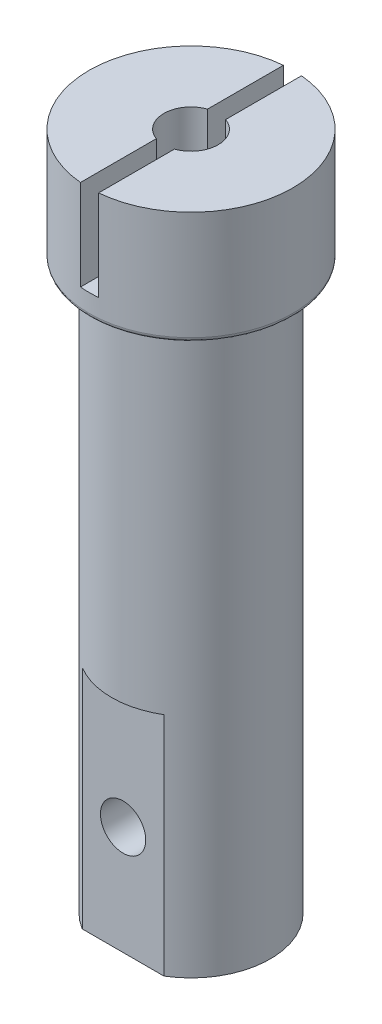
from build123d import *

# Parameters (mm, degrees)
STOCKDIAMETER_R        = 22.5
BASESTOCK_DEPTH        = 150
DIAMETERCUT_START      = -25
SKETCH11_OUTSIDE_W     = 79.588
SKETCH11_OUTSIDE_H     = 79.588
SKETCH11_OUTSIDE_R     = 17.5
DIAMETERCUT_DEPTH      = 126
SHAFTHOLE_R            = 6
MOTOR1SHAFTHOLE_DEPTH  = 151
SKETCH10_W             = 4
SKETCH10_H             = 20
SHAFTKEY_DEPTH         = 23.5
SHAFTKEY_DEPTH_BACK    = 23.5
ARMKEY_START           = -150
ARMKEYSKETCH_W         = 60
ARMKEYSKETCH_H         = 20
ARMKEY_DEPTH           = 50
ARM1MOUNTINGHOLE_START = 15
SKETCH13_R             = 5
ARM1MOUNTINGHOLE_DEPTH = 11.683375
FILLET1_R              = 1


with BuildPart() as part:
    # StockDiameter → BaseStock (new body)
    with BuildSketch(Plane(origin=(0, 0, 0), x_dir=(1, 0, 0), z_dir=(0, 1, 0))):
        Circle(STOCKDIAMETER_R)
    extrude(amount=-BASESTOCK_DEPTH)

    # Sketch11 outside → DiameterCut (cut, through all)
    with BuildSketch(Plane(origin=(0, 0, 0), x_dir=(1, 0, 0), z_dir=(0, 1, 0)).offset(DIAMETERCUT_START)):
        Rectangle(SKETCH11_OUTSIDE_W, SKETCH11_OUTSIDE_H)
        Circle(SKETCH11_OUTSIDE_R, mode=Mode.SUBTRACT)
    extrude(amount=-DIAMETERCUT_DEPTH, mode=Mode.SUBTRACT)

    # ShaftHole → Motor1ShaftHole (cut, through all)
    with BuildSketch(Plane(origin=(0, 0, 0), x_dir=(1, 0, 0), z_dir=(0, 1, 0))):
        Circle(SHAFTHOLE_R)
    extrude(amount=-MOTOR1SHAFTHOLE_DEPTH, mode=Mode.SUBTRACT)

    # Sketch10 → ShaftKey (cut, two sides)
    with BuildSketch(Plane.XY) as shaftkey_sk:
        with Locations((0, -10)):
            Rectangle(SKETCH10_W, SKETCH10_H)
    extrude(amount=SHAFTKEY_DEPTH, mode=Mode.SUBTRACT)
    extrude(shaftkey_sk.sketch, amount=-SHAFTKEY_DEPTH_BACK, mode=Mode.SUBTRACT)

    # ArmKeySketch → ArmKey (cut)
    with BuildSketch(Plane(origin=(0, 0, 0), x_dir=(1, 0, 0), z_dir=(0, 1, 0)).offset(ARMKEY_START)):
        with Locations((0, -25)):
            Rectangle(ARMKEYSKETCH_W, ARMKEYSKETCH_H)
    extrude(amount=ARMKEY_DEPTH, mode=Mode.SUBTRACT)

    # Sketch13 → Arm1MountingHole (cut)
    with BuildSketch(Plane.XY.offset(ARM1MOUNTINGHOLE_START)):
        with Locations((0, -126)):
            Circle(SKETCH13_R)
    extrude(amount=-ARM1MOUNTINGHOLE_DEPTH, mode=Mode.SUBTRACT)

    # Fillet1
    fillet1_edges = [part.edges().sort_by_distance(p)[0] for p in [
        (-22.5, -25, 0),
    ]]
    fillet(fillet1_edges, radius=FILLET1_R)


solid = part.part
